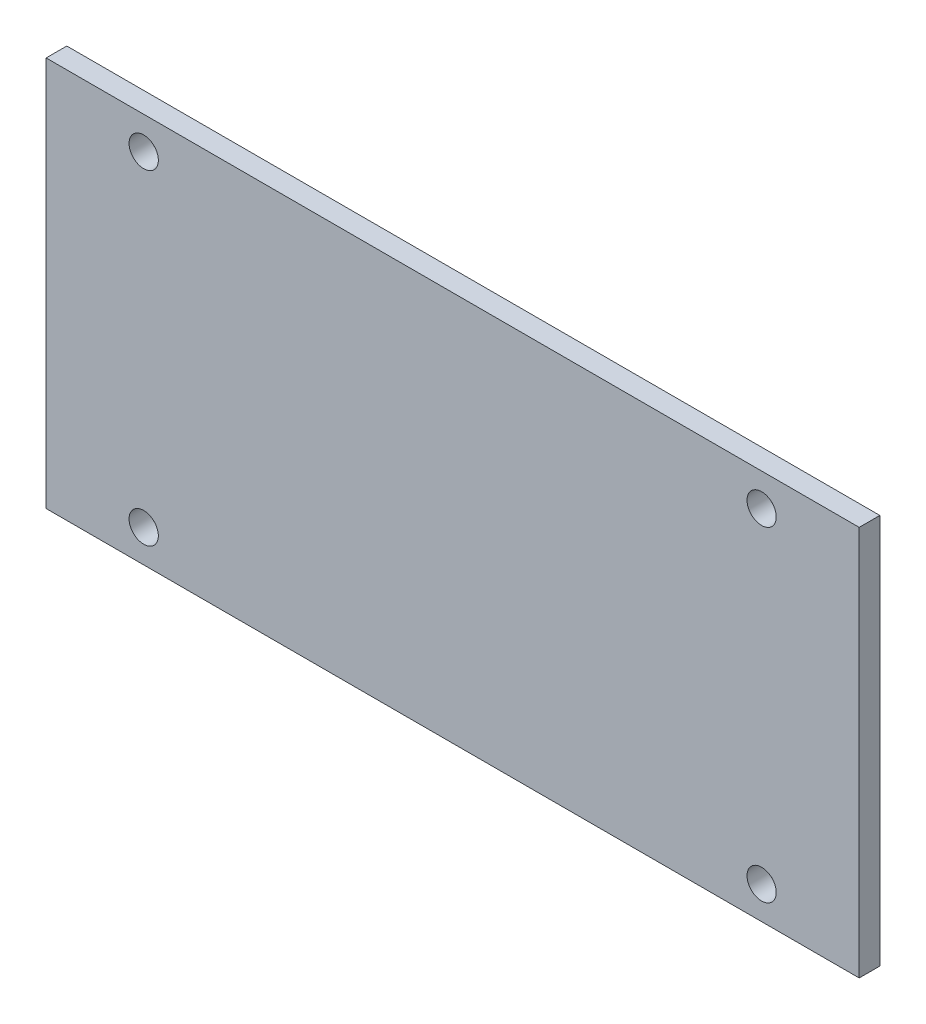
from build123d import *

# Parameters (mm, degrees)
SKETCH1_W           = 125
SKETCH1_H           = 60
BOSS_EXTRUDE1_DEPTH = 3.175
SKETCH2_R           = 2.25
CUT_EXTRUDE2_DEPTH  = 3.175


with BuildPart() as part:
    # Sketch1 → Boss-Extrude1 (new body)
    with BuildSketch(Plane.XY):
        Rectangle(SKETCH1_W, SKETCH1_H)
    extrude(amount=BOSS_EXTRUDE1_DEPTH)

    # Sketch2 → Cut-Extrude2 (cut)
    with BuildSketch(Plane.XY.offset(3.175)):
        with Locations((-47.5, 25)):
            Circle(SKETCH2_R)
        with Locations((-47.5, -25)):
            Circle(SKETCH2_R)
        with Locations((47.5, -25)):
            Circle(SKETCH2_R)
        with Locations((47.5, 25)):
            Circle(SKETCH2_R)
    extrude(amount=-CUT_EXTRUDE2_DEPTH, mode=Mode.SUBTRACT)


solid = part.part
